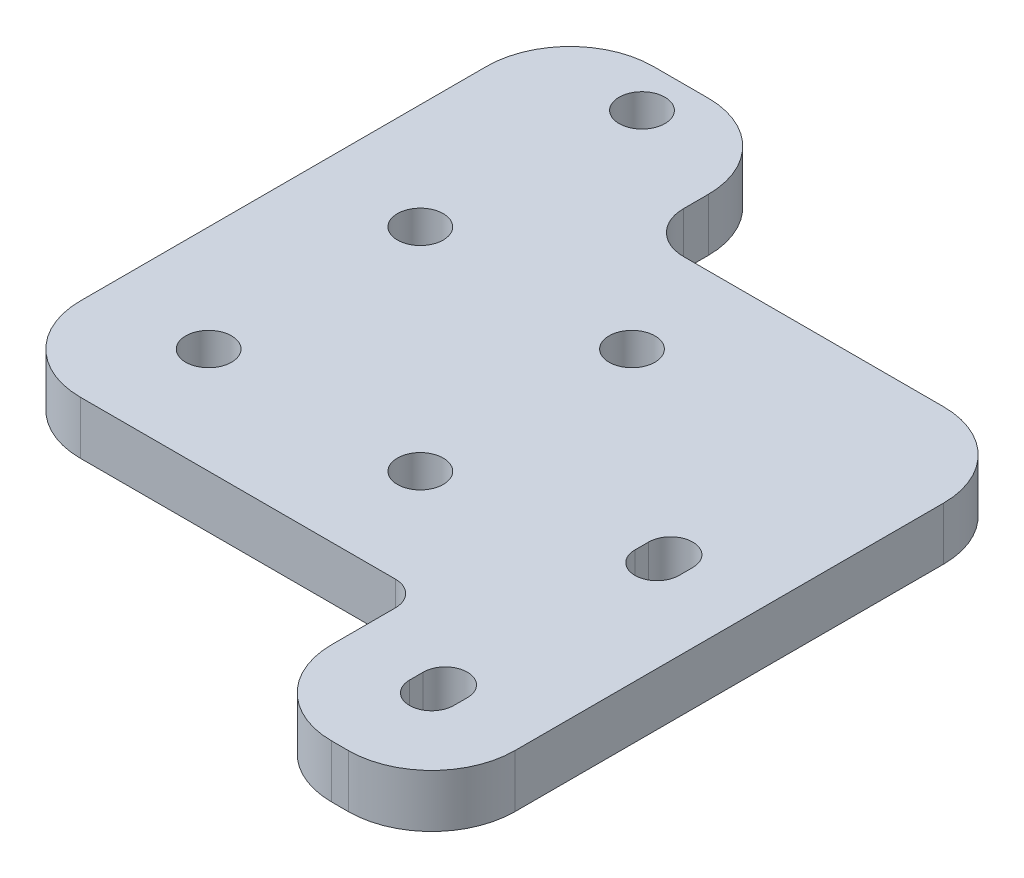
from build123d import *

# Parameters (mm, degrees)
BOSS_EXTRUDE1_DEPTH  = 6.35
M5_CLEARANCE_HOLE1_D = 5.5
CUT_EXTRUDE2_DEPTH   = 7.35
FILLET1_R            = 10
FILLET2_R            = 3
FILLET3_R            = 5


with BuildPart() as part:
    # Sketch1 → Boss-Extrude1 (new body)
    with BuildSketch(Plane(origin=(0, 0, 0), x_dir=(1, 0, 0), z_dir=(0, 1, 0))):
        Polygon((25.4, -25.4), (-25.4, -25.4), (-25.4, 25.4), (-25.4, 43.35), (1.2, 43.35), (1.2, 25.4), (25.4, 25.4), (47.4, 25.4), (47.4, -46.04), (36.4, -46.04), (25.4, -46.04), align=None)
    extrude(amount=BOSS_EXTRUDE1_DEPTH)

    # M5 Clearance Hole1 (through all)
    with Locations(Plane(origin=(0, 6.35, 0), x_dir=(1, 0, 0), z_dir=(0, 1, 0))):
        with Locations((-12.7, 12.7), (12.7, 12.7), (12.7, -12.7), (-12.7, -12.7), (-11.5, 38.1)):
            Hole(M5_CLEARANCE_HOLE1_D / 2)

    # Sketch7 → Cut-Extrude2 (cut, through all)
    with BuildSketch(Plane(origin=(0, 6.35, 0), x_dir=(1, 0, 0), z_dir=(0, 1, 0))):
        with BuildLine():
            Line((33.75, -33.4), (33.75, -35.04))
            ThreePointArc((33.75, -35.04), (36.4, -37.69), (39.05, -35.04))
            Line((39.05, -35.04), (39.05, -33.4))
            ThreePointArc((39.05, -33.4), (36.4, -30.75), (33.75, -33.4))
        make_face()
        with BuildLine():
            Line((33.75, -6.36), (33.75, -8))
            ThreePointArc((33.75, -8), (36.4, -10.65), (39.05, -8))
            Line((39.05, -8), (39.05, -6.36))
            ThreePointArc((39.05, -6.36), (36.4, -3.71), (33.75, -6.36))
        make_face()
    extrude(amount=-CUT_EXTRUDE2_DEPTH, mode=Mode.SUBTRACT)

    # Fillet1
    fillet1_edges = [part.edges().sort_by_distance(p)[0] for p in [
        (-25.4, 3.175, -43.35),
        (1.2, 3.175, -43.35),
        (47.4, 3.175, -25.4),
        (47.4, 3.175, 46.04),
        (25.4, 3.175, 46.04),
        (-25.4, 3.175, 25.4),
    ]]
    fillet(fillet1_edges, radius=FILLET1_R)

    # Fillet2
    fillet2_edges = [part.edges().sort_by_distance(p)[0] for p in [
        (25.4, 3.175, 25.4),
    ]]
    fillet(fillet2_edges, radius=FILLET2_R)

    # Fillet3
    fillet3_edges = [part.edges().sort_by_distance(p)[0] for p in [
        (1.2, 3.175, -25.4),
    ]]
    fillet(fillet3_edges, radius=FILLET3_R)


solid = part.part
